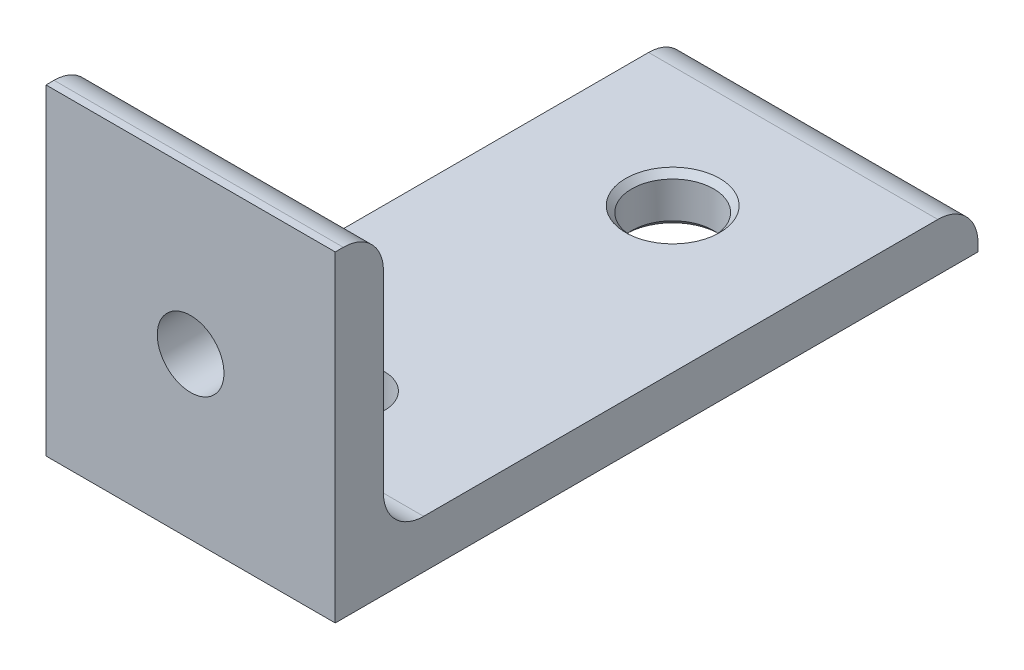
from build123d import *

# Parameters (mm, degrees)
BOSS_EXTRUDE1_DEPTH = 18
SKETCH2_R           = 5.1
SKETCH2_R_2         = 4.15
CUT_EXTRUDE1_DEPTH  = 7
SKETCH3_R           = 4.15
CUT_EXTRUDE2_DEPTH  = 7
FILLET1_R           = 5
CHAMFER1_SIZE       = 0.75


with BuildPart() as part:
    # Sketch1 → Boss-Extrude1 (new body, symmetric)
    with BuildSketch(Plane(origin=(0, 0, 0), x_dir=(0, 0, -1), z_dir=(1, 0, 0))):
        Polygon((0, 40), (0, 0), (80, 0), (80, 6), (6, 6), (6, 40), align=None)
    extrude(amount=BOSS_EXTRUDE1_DEPTH, both=True)

    # Sketch2 → Cut-Extrude1 (cut, through all)
    with BuildSketch(Plane(origin=(0, 6, 0), x_dir=(1, 0, 0), z_dir=(0, 1, 0))):
        with Locations((0, 60)):
            Circle(SKETCH2_R)
        with Locations((0, 20)):
            Circle(SKETCH2_R_2)
    extrude(amount=-CUT_EXTRUDE1_DEPTH, mode=Mode.SUBTRACT)

    # Sketch3 → Cut-Extrude2 (cut, through all)
    with BuildSketch(Plane(origin=(0, 0, -6), x_dir=(-1, 0, 0), z_dir=(0, 0, -1))):
        with Locations((0, 20)):
            Circle(SKETCH3_R)
    extrude(amount=-CUT_EXTRUDE2_DEPTH, mode=Mode.SUBTRACT)

    # Fillet1
    fillet1_edges = [part.edges().sort_by_distance(p)[0] for p in [
        (0, 40, -6),
        (0, 6, -6),
        (0, 6, -80),
    ]]
    fillet(fillet1_edges, radius=FILLET1_R)

    # Chamfer1
    chamfer1_edges = [part.edges().sort_by_distance(p)[0] for p in [
        (-5.1, 0, -60),
        (-5.1, 6, -60),
    ]]
    chamfer(chamfer1_edges, length=CHAMFER1_SIZE)


solid = part.part
